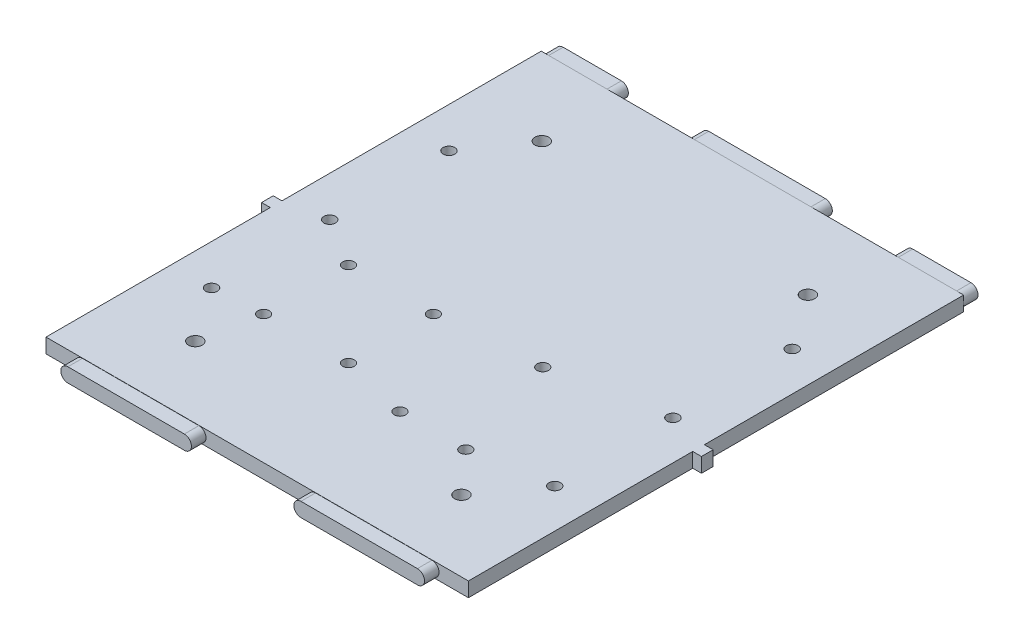
from build123d import *

# Parameters (mm, degrees)
SKETCH4_W           = 184.15
SKETCH4_H           = 215.9
BOSS_EXTRUDE2_DEPTH = 6.35
BOSS_EXTRUDE3_DEPTH = 6.35
BOSS_EXTRUDE4_DEPTH = 6.35
SKETCH7_W           = 5.08
SKETCH7_H           = 6.35
BOSS_EXTRUDE5_DEPTH = 3.81
SKETCH12_R          = 2.54
CUT_EXTRUDE4_DEPTH  = 7.35
SKETCH18_R          = 2.5
CUT_EXTRUDE8_DEPTH  = 10
SKETCH19_R          = 2.5
CUT_EXTRUDE9_DEPTH  = 10
SKETCH20_R          = 3
CUT_EXTRUDE10_DEPTH = 7.35
CUT_EXTRUDE11_DEPTH = 6.35
CUT_EXTRUDE12_DEPTH = 6.35
CUT_EXTRUDE13_DEPTH = 6.35
CUT_EXTRUDE14_DEPTH = 6.35
CUT_EXTRUDE15_DEPTH = 6.35


with BuildPart() as part:
    # Sketch4 → Boss-Extrude2 (new body)
    with BuildSketch(Plane(origin=(0, 0, 0), x_dir=(1, 0, 0), z_dir=(0, 1, 0))):
        with Locations((92.075, 107.95)):
            Rectangle(SKETCH4_W, SKETCH4_H)
    extrude(amount=BOSS_EXTRUDE2_DEPTH)

    # Sketch5 → Boss-Extrude3 (add)
    with BuildSketch(Plane.XY):
        with BuildLine():
            Line((15.875, 6.35), (66.675, 6.35))
            ThreePointArc((66.675, 6.35), (69.85, 3.175), (66.675, 0))
            Line((66.675, 0), (15.875, 0))
            ThreePointArc((15.875, 0), (12.7, 3.175), (15.875, 6.35))
        make_face()
    boss_extrude3 = extrude(amount=BOSS_EXTRUDE3_DEPTH)

    # Mirror1: Boss-Extrude3 across plane
    add(boss_extrude3.mirror(Plane(origin=(92.075, 0, 0), x_dir=(0, 0, 1), z_dir=(1, 0, 0))))

    # Sketch6 → Boss-Extrude4 (add)
    with BuildSketch(Plane(origin=(0, 0, -215.9), x_dir=(-1, 0, 0), z_dir=(0, 0, -1))):
        with BuildLine():
            Line((-117.475, 6.35), (-66.675, 6.35))
            ThreePointArc((-66.675, 6.35), (-63.5, 3.175), (-66.675, 0))
            Line((-66.675, 0), (-117.475, 0))
            ThreePointArc((-117.475, 0), (-120.65, 3.175), (-117.475, 6.35))
        make_face()
        with BuildLine():
            Line((-28.575, 6.35), (-3.175, 6.35))
            ThreePointArc((-3.175, 6.35), (0, 3.175), (-3.175, 0))
            Line((-3.175, 0), (-28.575, 0))
            ThreePointArc((-28.575, 0), (-31.75, 3.175), (-28.575, 6.35))
        make_face()
        with BuildLine():
            Line((-155.575, 6.35), (-180.975, 6.35))
            ThreePointArc((-180.975, 6.35), (-184.15, 3.175), (-180.975, 0))
            Line((-180.975, 0), (-155.575, 0))
            ThreePointArc((-155.575, 0), (-152.4, 3.175), (-155.575, 6.35))
        make_face()
    extrude(amount=BOSS_EXTRUDE4_DEPTH)

    # Sketch7 → Boss-Extrude5 (add)
    with BuildSketch(Plane(origin=(184.15, 0, 0), x_dir=(0, 0, -1), z_dir=(1, 0, 0))):
        with Locations((100.33, 3.175)):
            Rectangle(SKETCH7_W, SKETCH7_H)
    boss_extrude5 = extrude(amount=BOSS_EXTRUDE5_DEPTH)

    # Mirror3: Boss-Extrude5 across plane
    add(boss_extrude5.mirror(Plane.ZY.offset(-92.075)))

    # Sketch12 → Cut-Extrude4 (cut, through all)
    with BuildSketch(Plane.XZ):
        with Locations((17.528627724, -54.65)):
            Circle(SKETCH12_R)
        with Locations((167.15, -54.65)):
            Circle(SKETCH12_R)
        with Locations((167.15, -106.15)):
            Circle(SKETCH12_R)
        with Locations((17.528627724, -106.15)):
            Circle(SKETCH12_R)
        with Locations((17.528627724, -158.15)):
            Circle(SKETCH12_R)
        with Locations((167.15, -158.15)):
            Circle(SKETCH12_R)
    extrude(amount=-CUT_EXTRUDE4_DEPTH, mode=Mode.SUBTRACT)

    # Sketch18 → Cut-Extrude8 (cut)
    with BuildSketch(Plane(origin=(0, 6.35, 0), x_dir=(1, 0, 0), z_dir=(0, 1, 0))):
        with Locations((105.290220108, 49.015069715)):
            Circle(SKETCH18_R)
        with Locations((133.990220108, 49.015069715)):
            Circle(SKETCH18_R)
        with Locations((119.640220108, 96.915069715)):
            Circle(SKETCH18_R)
    extrude(amount=-CUT_EXTRUDE8_DEPTH, mode=Mode.SUBTRACT)

    # Sketch19 → Cut-Extrude9 (cut)
    with BuildSketch(Plane(origin=(0, 6.35, 0), x_dir=(1, 0, 0), z_dir=(0, 1, 0))):
        with Locations((75.754890742, 56.124247339)):
            Circle(SKETCH19_R)
        with Locations((38.754890742, 56.124247339)):
            Circle(SKETCH19_R)
        with Locations((75.754890742, 93.124247339)):
            Circle(SKETCH19_R)
        with Locations((38.754890742, 93.124247339)):
            Circle(SKETCH19_R)
    extrude(amount=-CUT_EXTRUDE9_DEPTH, mode=Mode.SUBTRACT)

    # Sketch20 → Cut-Extrude10 (cut, through all)
    with BuildSketch(Plane.XZ):
        with Locations((150.1, -182.048287602)):
            Circle(SKETCH20_R)
        with Locations((34.1, -182.048287602)):
            Circle(SKETCH20_R)
        with Locations((150.1, -31)):
            Circle(SKETCH20_R)
        with Locations((34.1, -31)):
            Circle(SKETCH20_R)
    extrude(amount=-CUT_EXTRUDE10_DEPTH, mode=Mode.SUBTRACT)

    # Sketch21 → Cut-Extrude11 (cut)
    with BuildSketch(Plane(origin=(0, 0, -222.25), x_dir=(-1, 0, 0), z_dir=(0, 0, -1))):
        with BuildLine():
            Line((-155.575, 6.35), (-180.975, 6.35))
            ThreePointArc((-180.975, 6.35), (-184.15, 3.175), (-180.975, 0))
            Line((-180.975, 0), (-155.575, 0))
            ThreePointArc((-155.575, 0), (-152.4, 3.175), (-155.575, 6.35))
        make_face()
        with BuildLine():
            Line((-155.575, 6.25), (-180.975, 6.25))
            ThreePointArc((-180.975, 6.25), (-184.05, 3.175), (-180.975, 0.1))
            Line((-180.975, 0.1), (-155.575, 0.1))
            ThreePointArc((-155.575, 0.1), (-152.5, 3.175), (-155.575, 6.25))
        make_face(mode=Mode.SUBTRACT)
    extrude(amount=-CUT_EXTRUDE11_DEPTH, mode=Mode.SUBTRACT)

    # Sketch22 → Cut-Extrude12 (cut)
    with BuildSketch(Plane(origin=(0, 0, -222.25), x_dir=(-1, 0, 0), z_dir=(0, 0, -1))):
        with BuildLine():
            Line((-66.675, 6.35), (-117.475, 6.35))
            ThreePointArc((-117.475, 6.35), (-120.65, 3.175), (-117.475, 0))
            Line((-117.475, 0), (-66.675, 0))
            ThreePointArc((-66.675, 0), (-63.5, 3.175), (-66.675, 6.35))
        make_face()
        with BuildLine():
            Line((-66.675, 6.25), (-117.475, 6.25))
            ThreePointArc((-117.475, 6.25), (-120.55, 3.175), (-117.475, 0.1))
            Line((-117.475, 0.1), (-66.675, 0.1))
            ThreePointArc((-66.675, 0.1), (-63.6, 3.175), (-66.675, 6.25))
        make_face(mode=Mode.SUBTRACT)
    extrude(amount=-CUT_EXTRUDE12_DEPTH, mode=Mode.SUBTRACT)

    # Sketch23 → Cut-Extrude13 (cut)
    with BuildSketch(Plane(origin=(0, 0, -222.25), x_dir=(-1, 0, 0), z_dir=(0, 0, -1))):
        with BuildLine():
            Line((-28.575, 0), (-3.175, 0))
            ThreePointArc((-3.175, 0), (0, 3.175), (-3.175, 6.35))
            Line((-3.175, 6.35), (-28.575, 6.35))
            ThreePointArc((-28.575, 6.35), (-31.75, 3.175), (-28.575, 0))
        make_face()
        with BuildLine():
            Line((-28.575, 0.1), (-3.175, 0.1))
            ThreePointArc((-3.175, 0.1), (-0.1, 3.175), (-3.175, 6.25))
            Line((-3.175, 6.25), (-28.575, 6.25))
            ThreePointArc((-28.575, 6.25), (-31.65, 3.175), (-28.575, 0.1))
        make_face(mode=Mode.SUBTRACT)
    extrude(amount=-CUT_EXTRUDE13_DEPTH, mode=Mode.SUBTRACT)

    # Sketch24 → Cut-Extrude14 (cut)
    with BuildSketch(Plane.XY.offset(6.35)):
        with BuildLine():
            Line((15.875, 0), (66.675, 0))
            ThreePointArc((66.675, 0), (69.85, 3.175), (66.675, 6.35))
            Line((66.675, 6.35), (15.875, 6.35))
            ThreePointArc((15.875, 6.35), (12.7, 3.175), (15.875, 0))
        make_face()
        with BuildLine():
            Line((15.875, 0.1), (66.675, 0.1))
            ThreePointArc((66.675, 0.1), (69.75, 3.175), (66.675, 6.25))
            Line((66.675, 6.25), (15.875, 6.25))
            ThreePointArc((15.875, 6.25), (12.8, 3.175), (15.875, 0.1))
        make_face(mode=Mode.SUBTRACT)
    extrude(amount=-CUT_EXTRUDE14_DEPTH, mode=Mode.SUBTRACT)

    # Sketch25 → Cut-Extrude15 (cut)
    with BuildSketch(Plane.XY.offset(6.35)):
        with BuildLine():
            Line((168.275, 6.35), (117.475, 6.35))
            ThreePointArc((117.475, 6.35), (114.3, 3.175), (117.475, 0))
            Line((117.475, 0), (168.275, 0))
            ThreePointArc((168.275, 0), (171.45, 3.175), (168.275, 6.35))
        make_face()
        with BuildLine():
            Line((168.275, 6.25), (117.475, 6.25))
            ThreePointArc((117.475, 6.25), (114.4, 3.175), (117.475, 0.1))
            Line((117.475, 0.1), (168.275, 0.1))
            ThreePointArc((168.275, 0.1), (171.35, 3.175), (168.275, 6.25))
        make_face(mode=Mode.SUBTRACT)
    extrude(amount=-CUT_EXTRUDE15_DEPTH, mode=Mode.SUBTRACT)


solid = part.part
